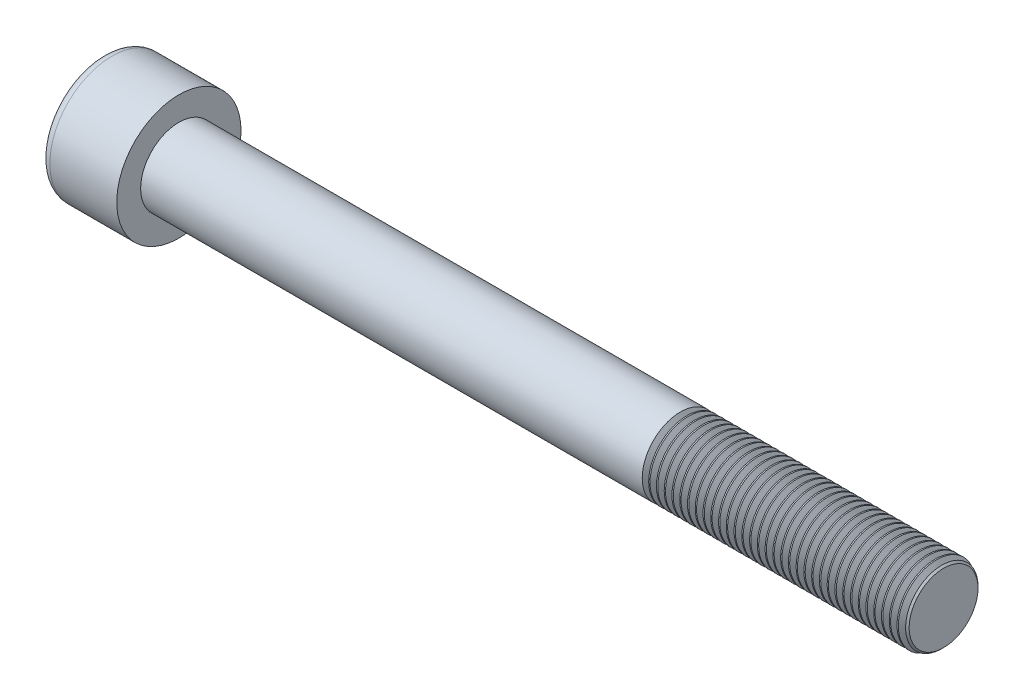
from build123d import *

# Parameters (mm, degrees)
SKETCH1_R           = 6.5
BASEHEAD_DEPTH      = 8
SKETCH2_R           = 4
BASEBODY_DEPTH      = 80
HEXAGONSOCKET_DEPTH = 4
TOPFILLET_R         = 1
CHAMFER1_SIZE       = 0.4
LPATTERN10_COUNT    = 34
LPATTERN10_PITCH    = 0.8118


with BuildPart() as part:
    # Sketch1 → BaseHead (new body)
    with BuildSketch(Plane(origin=(0, 0, 0), x_dir=(0, 0, -1), z_dir=(1, 0, 0))):
        Circle(SKETCH1_R)
    extrude(amount=BASEHEAD_DEPTH)

    # Sketch2 → BaseBody (add)
    with BuildSketch(Plane(origin=(8, 0, 0), x_dir=(0, 0, -1), z_dir=(1, 0, 0))):
        Circle(SKETCH2_R)
    extrude(amount=BASEBODY_DEPTH)

    # Sketch3 → HexagonSocket (cut)
    with BuildSketch(Plane(origin=(0, 0, 0), x_dir=(0, 0, -1), z_dir=(1, 0, 0))):
        Polygon((3.464101615, 0), (1.732050808, 3), (-1.732050808, 3), (-3.464101615, 0), (-1.732050808, -3), (1.732050808, -3), align=None)
    extrude(amount=HEXAGONSOCKET_DEPTH, mode=Mode.SUBTRACT)

    # Sketch4 → Cut-Revolve1 (revolve, cut)
    with BuildSketch(Plane(origin=(-4.19613823, 0.75, 0), x_dir=(-1, 0, 0), z_dir=(0, 0, 1))):
        Polygon((-8.19613823, 3.75), (-9.928189037, 0.75), (-8.19613823, 0.75), align=None)
    revolve(axis=Axis((0.838992387, 0, 0), (-1, 0, 0)), mode=Mode.SUBTRACT)

    # TopFillet
    topfillet_edges = [part.edges().sort_by_distance(p)[0] for p in [
        (0, 0, 6.5),
    ]]
    fillet(topfillet_edges, radius=TOPFILLET_R)

    # Chamfer1
    chamfer1_edges = [part.edges().sort_by_distance(p)[0] for p in [
        (88, 0, 4),
    ]]
    chamfer(chamfer1_edges, length=CHAMFER1_SIZE)

    # Sketch5 → Cut-Revolve10 (revolve, cut)
    with BuildSketch(Plane.XY):
        Polygon((87.6, 3.414133814), (87.93825, 4), (87.93825, 4.6765), (87.26175, 4.6765), (87.26175, 4), align=None)
    cut_revolve10 = revolve(axis=Axis((0, 0, 0), (1, 0, 0)), mode=Mode.SUBTRACT)

    # LPattern10: Cut-Revolve10 ×34
    with Locations(*[(-i * LPATTERN10_PITCH, 0, 0) for i in range(1, LPATTERN10_COUNT)]):
        add(cut_revolve10, mode=Mode.SUBTRACT)


solid = part.part
